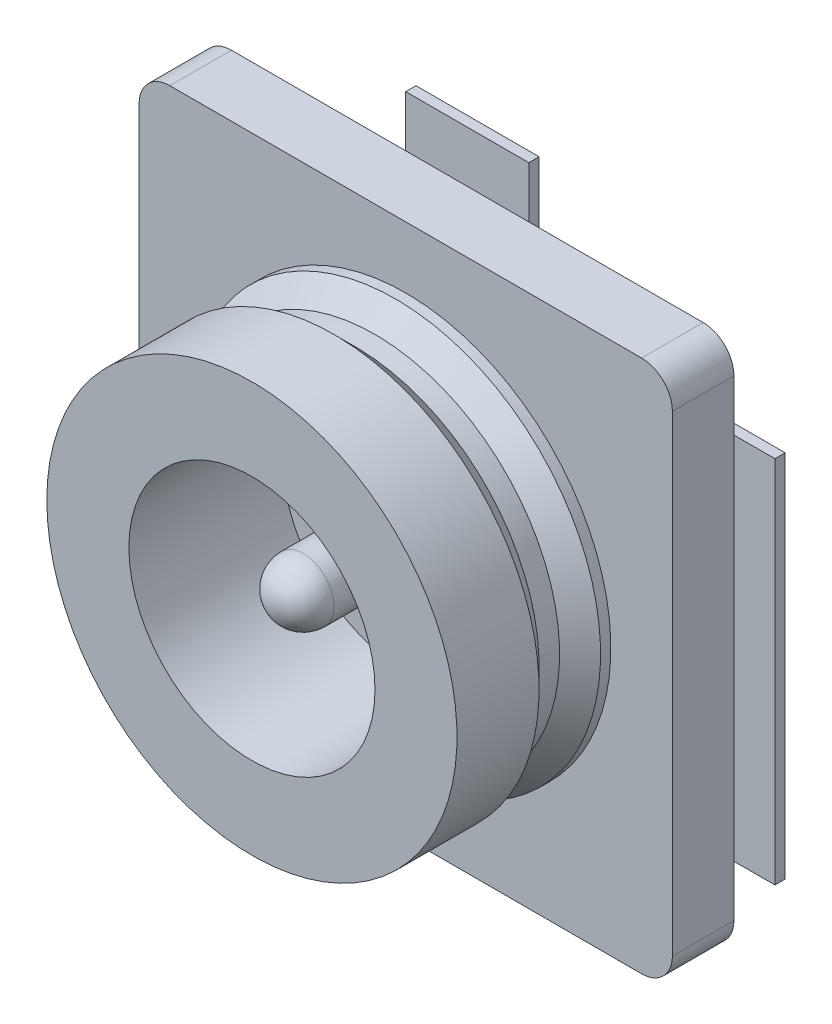
from build123d import *

# Parameters (mm, degrees)
SKETCH2_W           = 2.6
SKETCH2_H           = 2.6
BOSS_EXTRUDE2_DEPTH = 0.3
FILLET1_R           = 0.15
SKETCH3_W           = 0.5
SKETCH3_H           = 1.8
SKETCH3_W_2         = 0.6
SKETCH3_H_2         = 0.65
BOSS_EXTRUDE3_DEPTH = 0.05


with BuildPart() as part:
    # Sketch2 → Boss-Extrude2 (new body)
    with BuildSketch(Plane.XY):
        with Locations((1.3, 1.3)):
            Rectangle(SKETCH2_W, SKETCH2_H)
    extrude(amount=BOSS_EXTRUDE2_DEPTH)

    # Fillet1
    fillet1_edges = [part.edges().sort_by_distance(p)[0] for p in [
        (0, 0, 0.15),
        (2.6, 0, 0.15),
        (0, 2.6, 0.15),
        (2.6, 2.6, 0.15),
    ]]
    fillet(fillet1_edges, radius=FILLET1_R)

    # Sketch3 → Boss-Extrude3 (add)
    with BuildSketch(Plane.XY):
        with Locations((0.05, 1.3)):
            Rectangle(SKETCH3_W, SKETCH3_H)
        with Locations((2.55, 1.3)):
            Rectangle(SKETCH3_W, SKETCH3_H)
        with BuildLine():
            Line((1.475, 2.2), (1.6, 2.2))
            Line((1.6, 2.2), (1.6, 2.85))
            Line((1.6, 2.85), (1, 2.85))
            Line((1, 2.85), (1, 2.2))
            Line((1, 2.2), (1.125, 2.2))
            Line((1.125, 2.2), (1.125, 1.543669859))
            ThreePointArc((1.125, 1.543669859), (1.3, 1), (1.475, 1.543669859))
            Line((1.475, 1.543669859), (1.475, 2.2))
        make_face()
        with Locations((1.3, 0.075)):
            Rectangle(SKETCH3_W_2, SKETCH3_H_2)
    extrude(amount=-BOSS_EXTRUDE3_DEPTH)

    # Sketch4 → Revolve1 (revolve)
    with BuildSketch(Plane(origin=(1.3, 0, 0), x_dir=(0, 0, -1), z_dir=(1, 0, 0))):
        with BuildLine():
            Line((-0.3, 1.45), (-0.8, 1.45))
            ThreePointArc((-0.8, 1.45), (-0.906066017, 1.406066017), (-0.95, 1.3))
            Line((-0.95, 1.3), (-0.3, 1.3))
            Line((-0.3, 1.3), (-0.3, 1.45))
        make_face()
        Polygon((-0.3, 1.9), (-1.05, 1.9), (-1.05, 2.3), (-0.65, 2.3), (-0.55, 2.2), (-0.45, 2.2), (-0.35, 2.3), (-0.3, 2.3), align=None)
    revolve(axis=Axis((1.3, 1.3, -0.060709098), (0, 0, 1)))


solid = part.part
